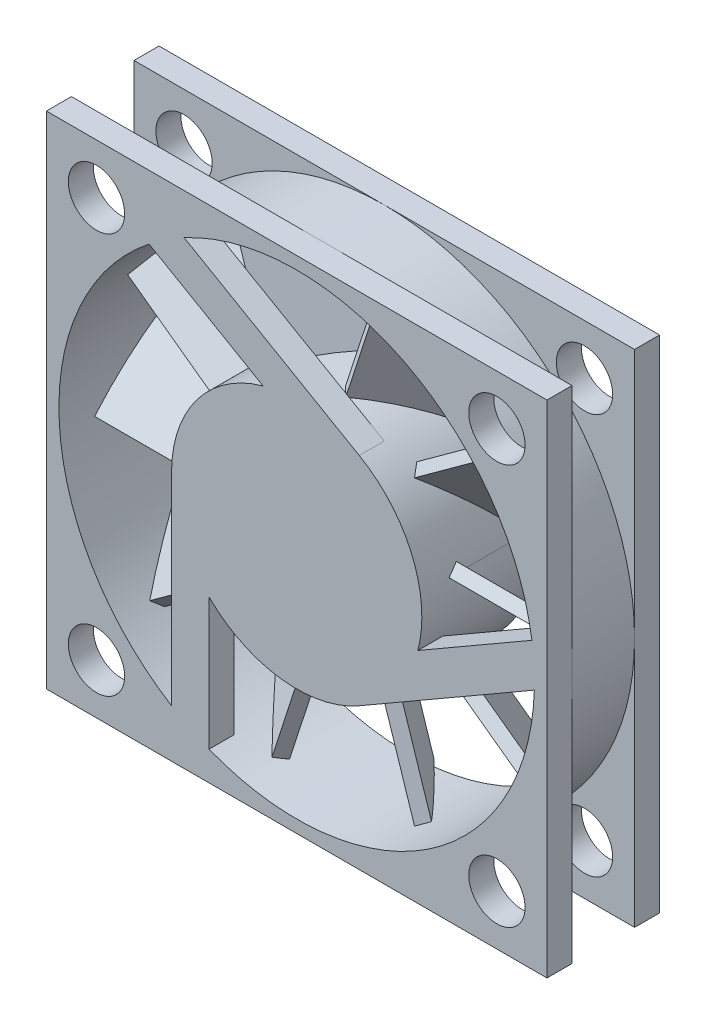
from build123d import *

# Parameters (mm, degrees)
SKETCH1_R                = 20
SKETCH1_R_2              = 19
BOSS_EXTRUDE1_DEPTH      = 2.5
BOSS_EXTRUDE1_DEPTH_BACK = 2.5
SKETCH2_W                = 40
SKETCH2_H                = 40
SKETCH2_R                = 2.25
SKETCH2_R_2              = 19
BOSS_EXTRUDE2_DEPTH      = 2
BOSS_EXTRUDE3_DEPTH      = 2
CIRPATTERN1_COUNT        = 3
SKETCH4_R                = 10
BOSS_EXTRUDE4_DEPTH      = 7
BOSS_EXTRUDE5_REACH      = 30.64
BOSS_EXTRUDE5_END_RADIUS = 18.5
CIRPATTERN2_COUNT        = 10


with BuildPart() as part:
    # Sketch1 → Boss-Extrude1 (new, two sides)
    with BuildSketch(Plane.XY) as boss_extrude1_sk:
        Circle(SKETCH1_R)
        Circle(SKETCH1_R_2, mode=Mode.SUBTRACT)
    extrude(amount=BOSS_EXTRUDE1_DEPTH)
    extrude(boss_extrude1_sk.sketch, amount=-BOSS_EXTRUDE1_DEPTH_BACK)

    # Sketch2 → Boss-Extrude2 (add)
    with BuildSketch(Plane.XY.offset(2.5)):
        Rectangle(SKETCH2_W, SKETCH2_H)
        with Locations((16, 16)):
            Circle(SKETCH2_R, mode=Mode.SUBTRACT)
        with Locations((-16, 16)):
            Circle(SKETCH2_R, mode=Mode.SUBTRACT)
        with Locations((-16, -16)):
            Circle(SKETCH2_R, mode=Mode.SUBTRACT)
        with Locations((16, -16)):
            Circle(SKETCH2_R, mode=Mode.SUBTRACT)
        Circle(SKETCH2_R_2, mode=Mode.SUBTRACT)
    boss_extrude2 = extrude(amount=BOSS_EXTRUDE2_DEPTH)

    # Mirror1: Boss-Extrude2 across plane
    add(boss_extrude2.mirror(Plane.XY))

    # Sketch3 → Boss-Extrude3 (add)
    with BuildSketch(Plane.XY.offset(4.5)):
        with BuildLine():
            Line((-10, 0), (-10, -16.155494421))
            ThreePointArc((-10, -16.155494421), (-8.533377795, -16.975908323), (-7, -17.663521733))
            Line((-7, -17.663521733), (-7, -7.141428429))
            ThreePointArc((-7, -7.141428429), (0.050003126, -9.999874984), (7.071067812, -7.071067812))
            Line((7.071067812, -7.071067812), (0, 0))
            Line((0, 0), (-10, 0))
        make_face()
    boss_extrude3 = extrude(amount=-BOSS_EXTRUDE3_DEPTH)

    # CirPattern1: Boss-Extrude3 ×3 about axis
    cirpattern1_axis = Axis((0, 0, 0), (0, 0, 1))
    for i in range(1, CIRPATTERN1_COUNT):
        add(boss_extrude3.rotate(cirpattern1_axis, i * 360 / CIRPATTERN1_COUNT))

    # Sketch4 → Boss-Extrude4 (add)
    with BuildSketch(Plane(origin=(0, 0, 2.5), x_dir=(-1, 0, 0), z_dir=(0, 0, -1))):
        Circle(SKETCH4_R)
    extrude(amount=BOSS_EXTRUDE4_DEPTH)

    # Boss-Extrude5: up to this cylinder (the profile starts inside it)
    boss_extrude5_end = Plane(origin=(0, 0, -1.146447), z_dir=(0, 0, 1)) * Cylinder(BOSS_EXTRUDE5_END_RADIUS, 99.28, mode=Mode.PRIVATE)
    # Sketch5 → Boss-Extrude5 (add, up to the surface)
    with BuildSketch(Plane(origin=(0, 0, 0), x_dir=(0, 0, -1), z_dir=(1, 0, 0)), mode=Mode.PRIVATE) as boss_extrude5_sk1:
        Polygon((-1.5, 2.207106781), (4.5, -3.792893219), (3.792893219, -4.5), (-2.207106781, 1.5), align=None)
    boss_extrude5_tool1 = extrude(boss_extrude5_sk1.sketch, amount=BOSS_EXTRUDE5_REACH, mode=Mode.PRIVATE) & boss_extrude5_end
    boss_extrude5 = boss_extrude5_tool1.solids().sort_by_distance((0, -1.146447, -1.146447))[0]
    add(boss_extrude5)

    # CirPattern2: Boss-Extrude5 ×10 about axis
    cirpattern2_axis = Axis((0, 0, 0), (0, 0, 1))
    for i in range(1, CIRPATTERN2_COUNT):
        add(boss_extrude5.rotate(cirpattern2_axis, i * 360 / CIRPATTERN2_COUNT))


solid = part.part
